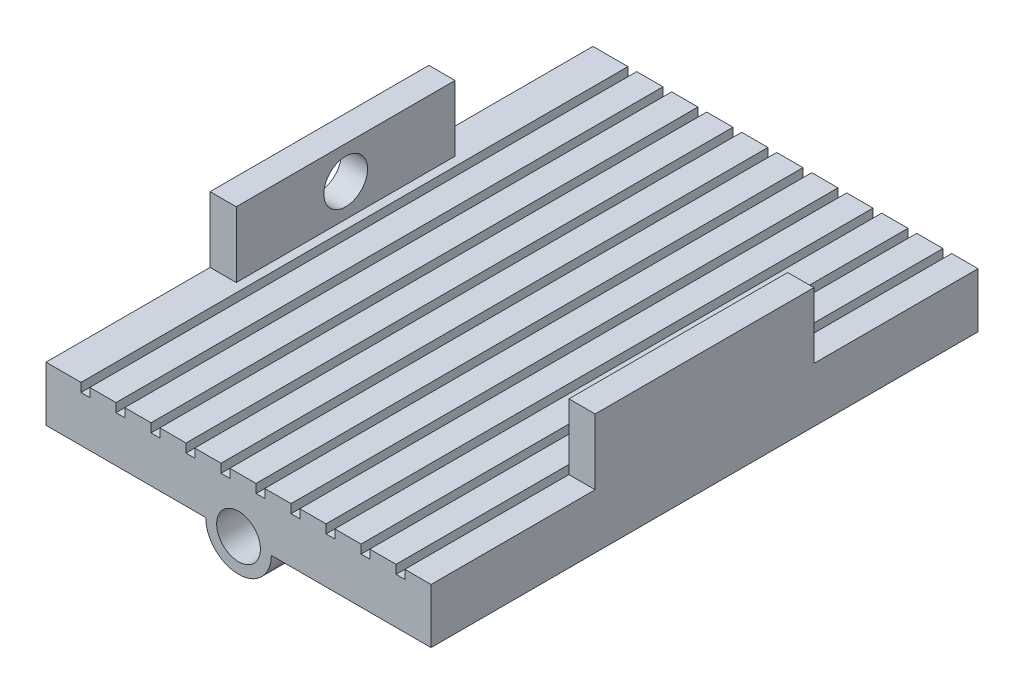
from build123d import *

# Parameters (mm, degrees)
BOSS_EXTRUDE1_DEPTH = 250
SKETCH3_R           = 10
CUT_EXTRUDE1_DEPTH  = 251
SKETCH4_W           = 4
SKETCH4_H           = 4
CUT_EXTRUDE2_DEPTH  = 251
LPATTERN1_COUNT     = 10
LPATTERN1_PITCH     = 16
SKETCH5_W           = 11.978375281
SKETCH5_H           = 100
BOSS_EXTRUDE2_DEPTH = 30
SKETCH6_R           = 10
CUT_EXTRUDE3_DEPTH  = 20


with BuildPart() as part:
    # Sketch1 → Boss-Extrude1 (new body)
    with BuildSketch(Plane.XY):
        with BuildLine():
            Line((15, 0), (88, 0))
            Line((88, 0), (88, 25))
            Line((88, 25), (-88, 25))
            Line((-88, 25), (-88, 0))
            Line((-88, 0), (-15, 0))
            ThreePointArc((-15, 0), (0, -15), (15, 0))
        make_face()
    extrude(amount=BOSS_EXTRUDE1_DEPTH)

    # Sketch3 → Cut-Extrude1 (cut, through all)
    with BuildSketch(Plane.XY.offset(250)):
        Circle(SKETCH3_R)
    extrude(amount=-CUT_EXTRUDE1_DEPTH, mode=Mode.SUBTRACT)

    # Sketch4 → Cut-Extrude2 (cut, through all)
    with BuildSketch(Plane.XY.offset(250)):
        with Locations((-70, 23)):
            Rectangle(SKETCH4_W, SKETCH4_H)
    cut_extrude2 = extrude(amount=-CUT_EXTRUDE2_DEPTH, mode=Mode.SUBTRACT)

    # LPattern1: Cut-Extrude2 ×10
    with Locations(*[(i * LPATTERN1_PITCH, 0, 0) for i in range(1, LPATTERN1_COUNT)]):
        add(cut_extrude2, mode=Mode.SUBTRACT)

    # Sketch5 → Boss-Extrude2 (add)
    with BuildSketch(Plane(origin=(0, 25, 0), x_dir=(1, 0, 0), z_dir=(0, 1, 0))):
        with Locations((-82.010812359, -125)):
            Rectangle(SKETCH5_W, SKETCH5_H)
    boss_extrude2 = extrude(amount=BOSS_EXTRUDE2_DEPTH)

    # Mirror1: Boss-Extrude2 across plane
    add(boss_extrude2.mirror(Plane.ZY))

    # Sketch6 → Cut-Extrude3 (cut)
    with BuildSketch(Plane.ZY.offset(88)):
        with Locations((125, 40)):
            Circle(SKETCH6_R)
    extrude(amount=-CUT_EXTRUDE3_DEPTH, mode=Mode.SUBTRACT)


solid = part.part
